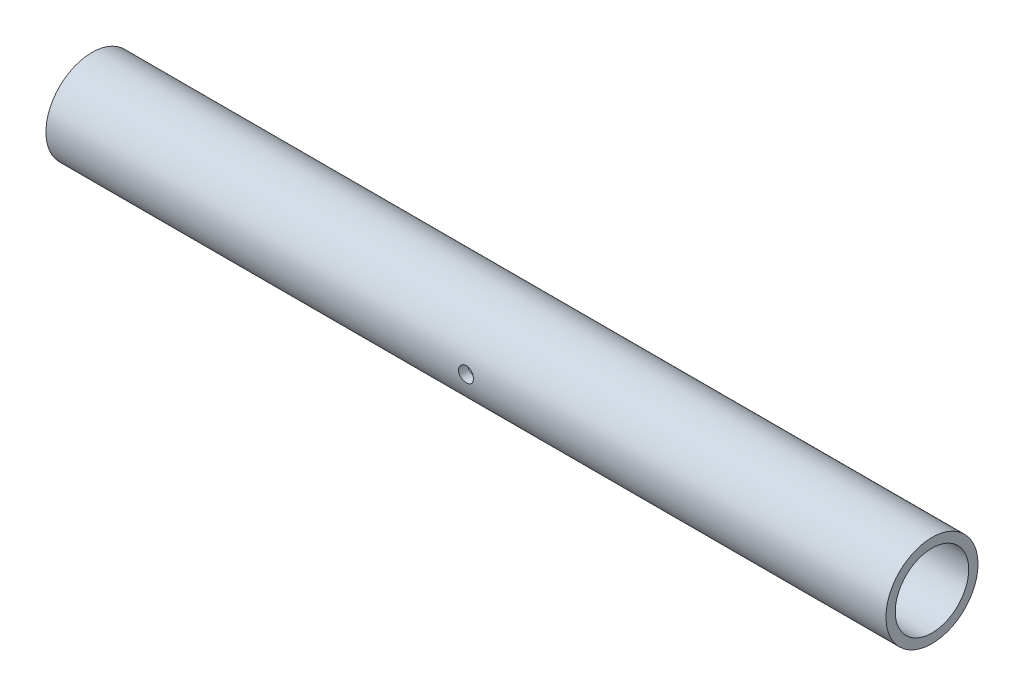
from build123d import *

# Parameters (mm, degrees)
SKETCH1_R                    = 16.7005
SKETCH1_R_2                  = 13.335
BOSS_EXTRUDE1_DEPTH          = 304.8
F_1_4_28_TAPPED_HOLE1_REACH  = 158.909
F_1_4_28_TAPPED_HOLE1_BORE_R = 2.7051


with BuildPart() as part:
    # Sketch1 → Boss-Extrude1 (new body)
    with BuildSketch(Plane(origin=(0, 0, 0), x_dir=(0, 0, -1), z_dir=(1, 0, 0))):
        with Locations(Location((0, 0, 0), (0, 0, 180))):
            Circle(SKETCH1_R)
        with Locations(Location((0, 0, 0), (0, 0, 180))):
            Circle(SKETCH1_R_2, mode=Mode.SUBTRACT)
    extrude(amount=BOSS_EXTRUDE1_DEPTH)

    # 1/4-28 Tapped Hole1 bore (on position points) → 1/4-28 Tapped Hole1 (cut, up to next)
    with BuildSketch(Plane(origin=(152.4, 0, 16.7005), x_dir=(1, 0, 0), z_dir=(0, 0, 1)), mode=Mode.PRIVATE) as f_1_4_28_tapped_hole1_sk1:
        Circle(F_1_4_28_TAPPED_HOLE1_BORE_R)
    f_1_4_28_tapped_hole1_tool1 = extrude(f_1_4_28_tapped_hole1_sk1.sketch, amount=-F_1_4_28_TAPPED_HOLE1_REACH, mode=Mode.PRIVATE) & part.part
    add(f_1_4_28_tapped_hole1_tool1.solids().sort_by_distance((152.4, 0, 16.7005))[0], mode=Mode.SUBTRACT)


solid = part.part
